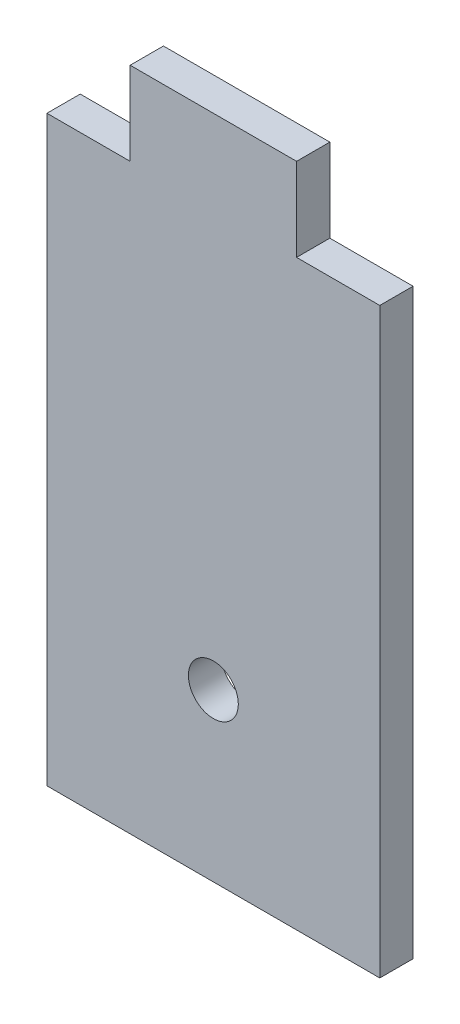
from build123d import *

# Parameters (mm, degrees)
CROQUIS1_R              = 1.5
SALIENTE_EXTRUIR1_DEPTH = 2


with BuildPart() as part:
    # Croquis1 → Saliente-Extruir1 (new body)
    with BuildSketch(Plane.XY):
        Polygon((-16.992209238, 17.558139535), (-21.992209238, 17.558139535), (-21.992209238, -17.441860465), (-1.992209238, -17.441860465), (-1.992209238, 17.558139535), (-6.992209238, 17.558139535), (-6.992209238, 22.558139535), (-16.992209238, 22.558139535), align=None)
        with Locations((-11.992209238, -7.441860465)):
            Circle(CROQUIS1_R, mode=Mode.SUBTRACT)
    extrude(amount=SALIENTE_EXTRUIR1_DEPTH)


solid = part.part
